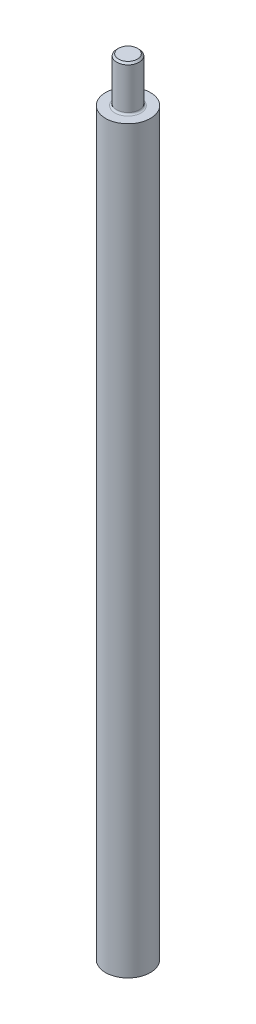
from build123d import *

# Parameters (mm, degrees)
SKETCH1_R           = 6.35
BOSS_EXTRUDE1_DEPTH = 104.775
SKETCH2_R           = 3.175
BOSS_EXTRUDE2_DEPTH = 12.7
FILLET1_R           = 0.508
CHAMFER1_SIZE       = 0.508


with BuildPart() as part:
    # Sketch1 → Boss-Extrude1 (new body, symmetric)
    with BuildSketch(Plane(origin=(0, 0, 0), x_dir=(1, 0, 0), z_dir=(0, 1, 0))):
        Circle(SKETCH1_R)
    extrude(amount=BOSS_EXTRUDE1_DEPTH, both=True)

    # Sketch2 → Boss-Extrude2 (add)
    with BuildSketch(Plane(origin=(0, 104.775, 0), x_dir=(1, 0, 0), z_dir=(0, 1, 0))):
        Circle(SKETCH2_R)
    extrude(amount=BOSS_EXTRUDE2_DEPTH)

    # Fillet1
    fillet1_edges = [part.edges().sort_by_distance(p)[0] for p in [
        (-3.175, 104.775, 0),
    ]]
    fillet(fillet1_edges, radius=FILLET1_R)

    # Chamfer1
    chamfer1_edges = [part.edges().sort_by_distance(p)[0] for p in [
        (-3.175, 117.475, 0),
    ]]
    chamfer(chamfer1_edges, length=CHAMFER1_SIZE)


solid = part.part
